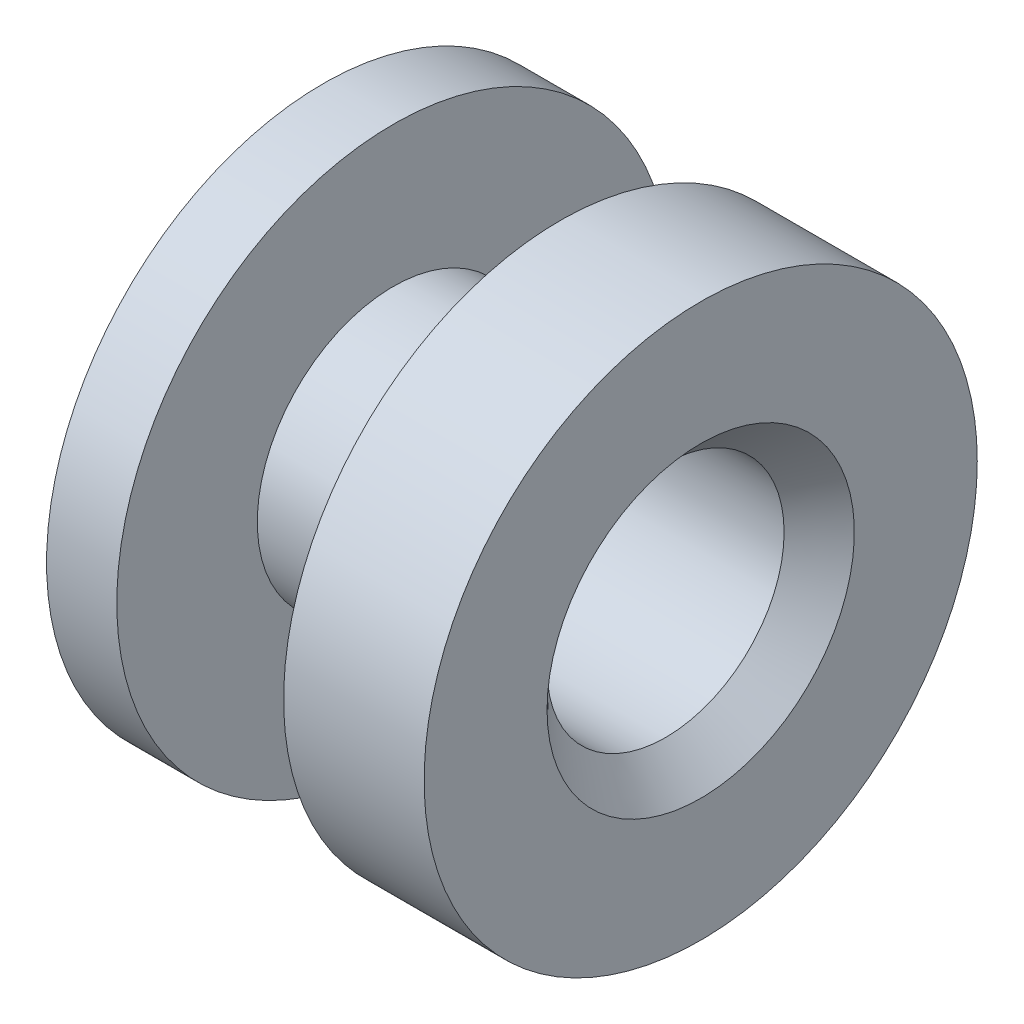
from build123d import *

# Parameters (mm, degrees)
SKETCH3_R               = 3.429
CUT_EXTRUDE1_DEPTH      = 1
CUT_EXTRUDE1_DEPTH_BACK = 11.922
CHAMFER1_SIZE           = 1.016


with BuildPart() as part:
    # Sketch2 → Revolve1 (revolve)
    with BuildSketch(Plane.XY):
        Polygon((10.922, 0), (0, 0), (0, 8.001), (2.032, 8.001), (2.032, 3.937), (6.858, 3.937), (6.858, 8.001), (10.922, 8.001), align=None)
    revolve(axis=Axis((10.922, 0, 0), (-1, 0, 0)))

    # Sketch3 → Cut-Extrude1 (cut, two sides)
    with BuildSketch(Plane(origin=(10.922, 0, 0), x_dir=(0, 0, -1), z_dir=(1, 0, 0))) as cut_extrude1_sk:
        Circle(SKETCH3_R)
    extrude(amount=CUT_EXTRUDE1_DEPTH, mode=Mode.SUBTRACT)
    extrude(cut_extrude1_sk.sketch, amount=-CUT_EXTRUDE1_DEPTH_BACK, mode=Mode.SUBTRACT)

    # Chamfer1
    chamfer1_edges = [part.edges().sort_by_distance(p)[0] for p in [
        (10.922, 0, 3.429),
    ]]
    chamfer(chamfer1_edges, length=CHAMFER1_SIZE)


solid = part.part
